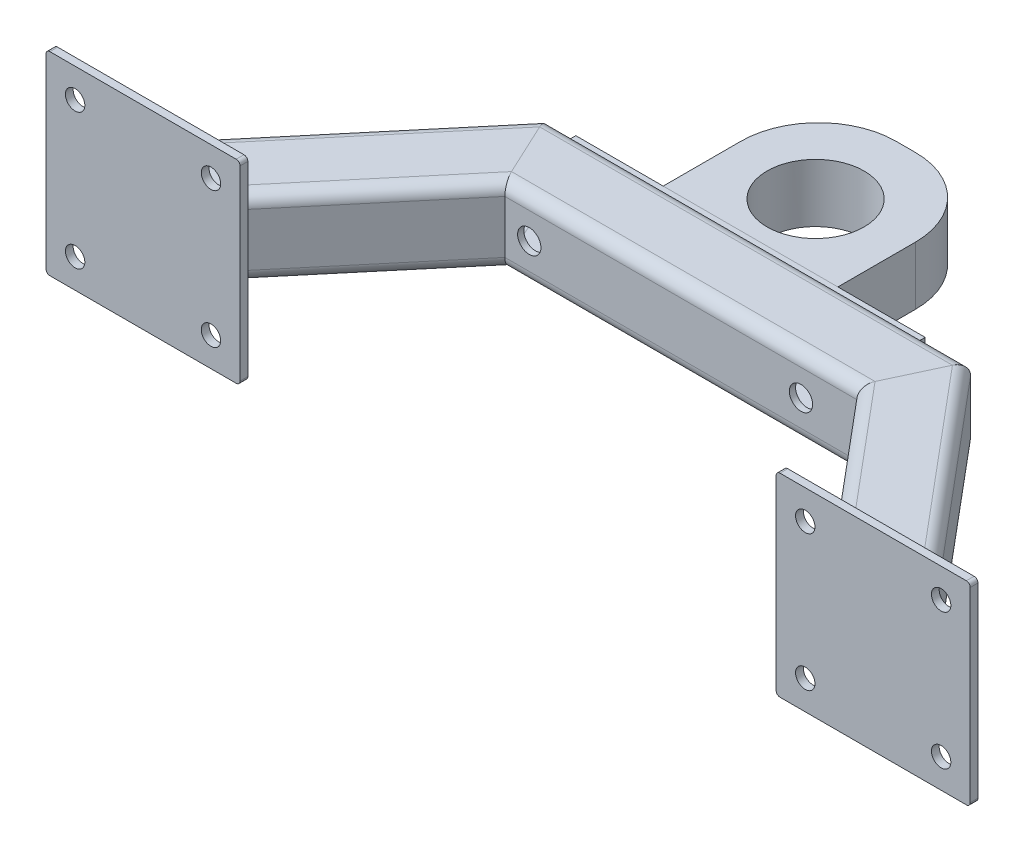
from build123d import *

# Parameters (mm, degrees)
TUBE_SQUARE_40_X_40_X_3_2_1_DEPTH   = 164.311010561
TUBE_SQUARE_40_X_40_X_3_2_1_2_DEPTH = 228.378344576
TUBE_SQUARE_40_X_40_X_3_2_1_3_DEPTH = 164.311010561
SKETCH13_W                          = 100
SKETCH13_H                          = 4
BOSS_EXTRUDE1_DEPTH                 = 50
BOSS_EXTRUDE1_DEPTH_BACK            = 50
BOSS_EXTRUDE1_2_DEPTH               = 50
BOSS_EXTRUDE1_2_DEPTH_BACK          = 50
PART_START                          = -6e-09
PART_RUN_ON_DEPTH                   = 3.72792
BODY_START                          = 164.311010579
BODY_3_RUN_ON_DEPTH                 = 3.72792
SKETCH14_W                          = 180
SKETCH14_H                          = 30
BOSS_EXTRUDE2_DEPTH                 = 4
SKETCH15_W                          = 90
SKETCH15_H                          = 30
BOSS_EXTRUDE3_DEPTH                 = 80
FILLET1_R                           = 40
FILLET2_R                           = 40
SKETCH16_R                          = 25
CUT_EXTRUDE1_DEPTH                  = 30
SKETCH17_R                          = 6
CUT_EXTRUDE2_DEPTH                  = 458.239355126
SKETCH18_R                          = 5
CUT_EXTRUDE3_DEPTH                  = 4
FILLET3_R                           = 2
FILLET4_R                           = 2
FILLET5_R                           = 2


with BuildPart() as part:
    # Sketch11 → Tube (square) 40 X 40 X 3.2(1) (new body)
    with BuildSketch(Plane(origin=(0, 0, 0), x_dir=(-0.7660444431189797, 0, -0.6427876096865373), z_dir=(0.6427876096865374, 0, -0.7660444431189798))):
        with BuildLine():
            Line((-13.6, -20), (13.6, -20))
            ThreePointArc((13.6, -20), (18.1254834, -18.1254834), (20, -13.6))
            Line((20, -13.6), (20, 13.6))
            ThreePointArc((20, 13.6), (18.1254834, 18.1254834), (13.6, 20))
            Line((13.6, 20), (-13.6, 20))
            ThreePointArc((-13.6, 20), (-18.1254834, 18.1254834), (-20, 13.6))
            Line((-20, 13.6), (-20, -13.6))
            ThreePointArc((-20, -13.6), (-18.1254834, -18.1254834), (-13.6, -20))
        make_face()
        with BuildLine():
            Line((-13.6, -16.8), (13.6, -16.8))
            ThreePointArc((13.6, -16.8), (15.8627417, -15.8627417), (16.8, -13.6))
            Line((16.8, -13.6), (16.8, 13.6))
            ThreePointArc((16.8, 13.6), (15.8627417, 15.8627417), (13.6, 16.8))
            Line((13.6, 16.8), (-13.6, 16.8))
            ThreePointArc((-13.6, 16.8), (-15.8627417, 15.8627417), (-16.8, 13.6))
            Line((-16.8, 13.6), (-16.8, -13.6))
            ThreePointArc((-16.8, -13.6), (-15.8627417, -15.8627417), (-13.6, -16.8))
        make_face(mode=Mode.SUBTRACT)
    extrude(amount=TUBE_SQUARE_40_X_40_X_3_2_1_DEPTH)

    # Tube (square) 40 X 40 X 3.2(1) mitre 1
    split(bisect_by=Plane(origin=(96.496457585, 0, -115), x_dir=(0, -1, 0), z_dir=(-0.906307787, 0, 0.422618262)), keep=Keep.TOP)

    # Sketch11 → part run on (add)
    with BuildSketch(Plane(origin=(0, 0, 0), x_dir=(-0.7660444431189797, 0, -0.6427876096865373), z_dir=(0.6427876096865374, 0, -0.7660444431189798)).offset(PART_START)):
        with BuildLine():
            Line((-13.6, -20), (13.6, -20))
            ThreePointArc((13.6, -20), (18.1254834, -18.1254834), (20, -13.6))
            Line((20, -13.6), (20, 13.6))
            ThreePointArc((20, 13.6), (18.1254834, 18.1254834), (13.6, 20))
            Line((13.6, 20), (-13.6, 20))
            ThreePointArc((-13.6, 20), (-18.1254834, 18.1254834), (-20, 13.6))
            Line((-20, 13.6), (-20, -13.6))
            ThreePointArc((-20, -13.6), (-18.1254834, -18.1254834), (-13.6, -20))
        make_face()
        with BuildLine():
            Line((-13.6, -16.8), (13.6, -16.8))
            ThreePointArc((13.6, -16.8), (15.8627417, -15.8627417), (16.8, -13.6))
            Line((16.8, -13.6), (16.8, 13.6))
            ThreePointArc((16.8, 13.6), (15.8627417, 15.8627417), (13.6, 16.8))
            Line((13.6, 16.8), (-13.6, 16.8))
            ThreePointArc((-13.6, 16.8), (-15.8627417, 15.8627417), (-16.8, 13.6))
            Line((-16.8, 13.6), (-16.8, -13.6))
            ThreePointArc((-16.8, -13.6), (-15.8627417, -15.8627417), (-13.6, -16.8))
        make_face(mode=Mode.SUBTRACT)
    extrude(amount=-PART_RUN_ON_DEPTH)

    # Trim/Extend1
    split(bisect_by=Plane(origin=(8.390996312, 0, -10), x_dir=(0, 1, 0), z_dir=(0, 0, -1)), keep=Keep.TOP)


with BuildPart() as body_2:
    # Sketch11 on segment 2 (carried to segment 2) → Tube _square_ 40 X 40 X 3.2_1 2 (new body)
    with BuildSketch(Plane(origin=(82.307285297, 0, -115), x_dir=(0, 0, -1), z_dir=(1, 0, 0))):
        with BuildLine():
            Line((-13.6, -20), (13.6, -20))
            ThreePointArc((13.6, -20), (18.1254834, -18.1254834), (20, -13.6))
            Line((20, -13.6), (20, 13.6))
            ThreePointArc((20, 13.6), (18.1254834, 18.1254834), (13.6, 20))
            Line((13.6, 20), (-13.6, 20))
            ThreePointArc((-13.6, 20), (-18.1254834, 18.1254834), (-20, 13.6))
            Line((-20, 13.6), (-20, -13.6))
            ThreePointArc((-20, -13.6), (-18.1254834, -18.1254834), (-13.6, -20))
        make_face()
        with BuildLine():
            Line((-13.6, -16.8), (13.6, -16.8))
            ThreePointArc((13.6, -16.8), (15.8627417, -15.8627417), (16.8, -13.6))
            Line((16.8, -13.6), (16.8, 13.6))
            ThreePointArc((16.8, 13.6), (15.8627417, 15.8627417), (13.6, 16.8))
            Line((13.6, 16.8), (-13.6, 16.8))
            ThreePointArc((-13.6, 16.8), (-15.8627417, 15.8627417), (-16.8, 13.6))
            Line((-16.8, 13.6), (-16.8, -13.6))
            ThreePointArc((-16.8, -13.6), (-15.8627417, -15.8627417), (-13.6, -16.8))
        make_face(mode=Mode.SUBTRACT)
    extrude(amount=TUBE_SQUARE_40_X_40_X_3_2_1_2_DEPTH)

    # Tube _square_ 40 X 40 X 3.2_1 2 mitre 1
    split(bisect_by=Plane(origin=(96.496457585, 0, -115), x_dir=(0, 1, 0), z_dir=(0.906307787, 0, -0.422618262)), keep=Keep.TOP)

    # Tube _square_ 40 X 40 X 3.2_1 2 mitre 2
    split(bisect_by=Plane(origin=(296.496457585, 0, -115), x_dir=(0, -1, 0), z_dir=(-0.906307787, 0, -0.422618262)), keep=Keep.TOP)


with BuildPart() as body_3:
    # Sketch11 on segment 3 (carried to segment 3) → Tube _square_ 40 X 40 X 3.2_1 3 (new body)
    with BuildSketch(Plane(origin=(287.375833447, 0, -125.869536584), x_dir=(0.766044443, 0, -0.64278761), z_dir=(0.64278761, 0, 0.766044443))):
        with BuildLine():
            Line((-13.6, -20), (13.6, -20))
            ThreePointArc((13.6, -20), (18.1254834, -18.1254834), (20, -13.6))
            Line((20, -13.6), (20, 13.6))
            ThreePointArc((20, 13.6), (18.1254834, 18.1254834), (13.6, 20))
            Line((13.6, 20), (-13.6, 20))
            ThreePointArc((-13.6, 20), (-18.1254834, 18.1254834), (-20, 13.6))
            Line((-20, 13.6), (-20, -13.6))
            ThreePointArc((-20, -13.6), (-18.1254834, -18.1254834), (-13.6, -20))
        make_face()
        with BuildLine():
            Line((-13.6, -16.8), (13.6, -16.8))
            ThreePointArc((13.6, -16.8), (15.8627417, -15.8627417), (16.8, -13.6))
            Line((16.8, -13.6), (16.8, 13.6))
            ThreePointArc((16.8, 13.6), (15.8627417, 15.8627417), (13.6, 16.8))
            Line((13.6, 16.8), (-13.6, 16.8))
            ThreePointArc((-13.6, 16.8), (-15.8627417, 15.8627417), (-16.8, 13.6))
            Line((-16.8, 13.6), (-16.8, -13.6))
            ThreePointArc((-16.8, -13.6), (-15.8627417, -15.8627417), (-13.6, -16.8))
        make_face(mode=Mode.SUBTRACT)
    extrude(amount=TUBE_SQUARE_40_X_40_X_3_2_1_3_DEPTH)

    # Tube _square_ 40 X 40 X 3.2_1 3 mitre 1
    split(bisect_by=Plane(origin=(296.496457585, 0, -115), x_dir=(0, 1, 0), z_dir=(0.906307787, 0, 0.422618262)), keep=Keep.TOP)

    # Sketch11 on segment 3 (carried to segment 3) → body 3 run on (add)
    with BuildSketch(Plane(origin=(287.375833447, 0, -125.869536584), x_dir=(0.766044443, 0, -0.64278761), z_dir=(0.64278761, 0, 0.766044443)).offset(BODY_START)):
        with BuildLine():
            Line((-13.6, -20), (13.6, -20))
            ThreePointArc((13.6, -20), (18.1254834, -18.1254834), (20, -13.6))
            Line((20, -13.6), (20, 13.6))
            ThreePointArc((20, 13.6), (18.1254834, 18.1254834), (13.6, 20))
            Line((13.6, 20), (-13.6, 20))
            ThreePointArc((-13.6, 20), (-18.1254834, 18.1254834), (-20, 13.6))
            Line((-20, 13.6), (-20, -13.6))
            ThreePointArc((-20, -13.6), (-18.1254834, -18.1254834), (-13.6, -20))
        make_face()
        with BuildLine():
            Line((-13.6, -16.8), (13.6, -16.8))
            ThreePointArc((13.6, -16.8), (15.8627417, -15.8627417), (16.8, -13.6))
            Line((16.8, -13.6), (16.8, 13.6))
            ThreePointArc((16.8, 13.6), (15.8627417, 15.8627417), (13.6, 16.8))
            Line((13.6, 16.8), (-13.6, 16.8))
            ThreePointArc((-13.6, 16.8), (-15.8627417, 15.8627417), (-16.8, 13.6))
            Line((-16.8, 13.6), (-16.8, -13.6))
            ThreePointArc((-16.8, -13.6), (-15.8627417, -15.8627417), (-13.6, -16.8))
        make_face(mode=Mode.SUBTRACT)
    extrude(amount=BODY_3_RUN_ON_DEPTH)

    # Trim/Extend2
    split(bisect_by=Plane(origin=(384.601918859, 0, -10), x_dir=(0, 1, 0), z_dir=(0, 0, -1)), keep=Keep.TOP)


with BuildPart() as body_4:
    # Sketch13 → Boss-Extrude1 (new, two sides)
    with BuildSketch(Plane(origin=(0, 0, 0), x_dir=(1, 0, 0), z_dir=(0, 1, 0))) as boss_extrude1_sk:
        with Locations((8.390996312, 8)):
            Rectangle(SKETCH13_W, SKETCH13_H)
    extrude(amount=BOSS_EXTRUDE1_DEPTH)
    extrude(boss_extrude1_sk.sketch, amount=-BOSS_EXTRUDE1_DEPTH_BACK)


with BuildPart() as body_5:
    # Sketch13 → Boss-Extrude1 2 (new, two sides)
    with BuildSketch(Plane(origin=(0, 0, 0), x_dir=(1, 0, 0), z_dir=(0, 1, 0))) as boss_extrude1_2_sk:
        with Locations((384.601918859, 8)):
            Rectangle(SKETCH13_W, SKETCH13_H)
    extrude(amount=BOSS_EXTRUDE1_2_DEPTH)
    extrude(boss_extrude1_2_sk.sketch, amount=-BOSS_EXTRUDE1_2_DEPTH_BACK)


with BuildPart() as body_6:
    # Sketch14 → Boss-Extrude2 (new body)
    with BuildSketch(Plane(origin=(0, 0, -135), x_dir=(-1, 0, 0), z_dir=(0, 0, -1))):
        with Locations((-188.390372398, 0)):
            Rectangle(SKETCH14_W, SKETCH14_H)
    extrude(amount=BOSS_EXTRUDE2_DEPTH)


with BuildPart() as body_7:
    # Sketch15 → Boss-Extrude3 (new body)
    with BuildSketch(Plane(origin=(0, 0, -139), x_dir=(-1, 0, 0), z_dir=(0, 0, -1))):
        with Locations((-188.390372398, 0)):
            Rectangle(SKETCH15_W, SKETCH15_H)
    extrude(amount=BOSS_EXTRUDE3_DEPTH)

    # Fillet1
    fillet1_edges = [body_7.edges().sort_by_distance(p)[0] for p in [
        (233.390372398, 0, -219),
    ]]
    fillet(fillet1_edges, radius=FILLET1_R)

    # Fillet2
    fillet2_edges = [body_7.edges().sort_by_distance(p)[0] for p in [
        (143.390372398, 0, -219),
    ]]
    fillet(fillet2_edges, radius=FILLET2_R)

    # Sketch16 → Cut-Extrude1 (cut)
    with BuildSketch(Plane.XZ.offset(15)):
        with Locations((188.390372398, -172.516002279)):
            Circle(SKETCH16_R)
    extrude(amount=-CUT_EXTRUDE1_DEPTH, mode=Mode.SUBTRACT)


with BuildPart() as cut_extrude2_tool:
    # Sketch17 → Cut-Extrude2 (new, through all)
    with BuildSketch(Plane(origin=(0, 0, -139), x_dir=(-1, 0, 0), z_dir=(0, 0, -1))):
        with Locations((-258.390372398, 0)):
            Circle(SKETCH17_R)
        with Locations((-118.390372398, 0)):
            Circle(SKETCH17_R)
    extrude(amount=-CUT_EXTRUDE2_DEPTH)


with BuildPart() as body_2_1:
    add(body_2.part)

    # Cut-Extrude2: cut by cut_extrude2_tool
    add(cut_extrude2_tool.part, mode=Mode.SUBTRACT)


with BuildPart() as body_6_1:
    add(body_6.part)

    # Cut-Extrude2: cut by cut_extrude2_tool
    add(cut_extrude2_tool.part, mode=Mode.SUBTRACT)


with BuildPart() as cut_extrude3_tool:
    # Sketch18 → Cut-Extrude3 (new body)
    with BuildSketch(Plane.XY.offset(-6)):
        with Locations((349.601918859, -35)):
            Circle(SKETCH18_R)
        with Locations((419.601918859, -35)):
            Circle(SKETCH18_R)
        with Locations((419.601918859, 35)):
            Circle(SKETCH18_R)
        with Locations((349.601918859, 35)):
            Circle(SKETCH18_R)
        with Locations((43.390996312, 35)):
            Circle(SKETCH18_R)
        with Locations((43.390996312, -35)):
            Circle(SKETCH18_R)
        with Locations((-26.609003688, -35)):
            Circle(SKETCH18_R)
        with Locations((-26.609003688, 35)):
            Circle(SKETCH18_R)
    extrude(amount=-CUT_EXTRUDE3_DEPTH)


with BuildPart() as body_4_1:
    add(body_4.part)

    # Cut-Extrude3: cut by cut_extrude3_tool
    add(cut_extrude3_tool.part, mode=Mode.SUBTRACT)

    # Fillet4
    fillet4_edges = [body_4_1.edges().sort_by_distance(p)[0] for p in [
        (58.390996312, -50, -8),
        (58.390996312, 50, -8),
        (-41.609003688, -50, -8),
    ]]
    fillet(fillet4_edges, radius=FILLET4_R)

    # Fillet5
    fillet5_edges = [body_4_1.edges().sort_by_distance(p)[0] for p in [
        (-41.609003688, 50, -8),
    ]]
    fillet(fillet5_edges, radius=FILLET5_R)


with BuildPart() as body_5_1:
    add(body_5.part)

    # Cut-Extrude3: cut by cut_extrude3_tool
    add(cut_extrude3_tool.part, mode=Mode.SUBTRACT)

    # Fillet3
    fillet3_edges = [body_5_1.edges().sort_by_distance(p)[0] for p in [
        (334.601918859, 50, -8),
        (434.601918859, -50, -8),
        (434.601918859, 50, -8),
        (334.601918859, -50, -8),
    ]]
    fillet(fillet3_edges, radius=FILLET3_R)


solid = Compound([part.part, body_3.part, body_7.part, body_2_1.part, body_6_1.part, body_4_1.part, body_5_1.part])
